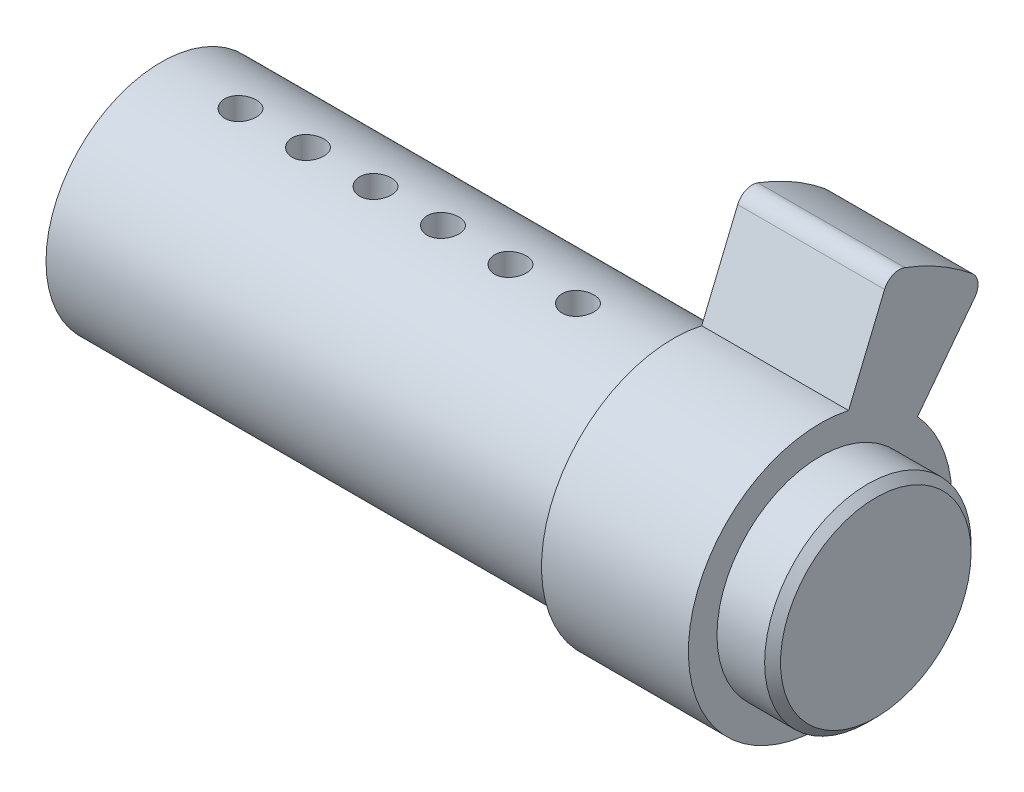
from build123d import *

# Parameters (mm, degrees)
SKETCH1_R           = 7.25
OUTSIDE_DIA_DEPTH   = 32.25
SKETCH2_W           = 2.5
SKETCH2_H           = 8.25
KEYHOLE_DEPTH       = 33.25
SKETCH3_R           = 1
PIN_1_DEPTH         = 35
LPATTERN1_COUNT     = 6
LPATTERN1_PITCH     = 4.25
CAM_DEPTH           = 9.25
FILLET_R1_R         = 1
SKETCH6_R           = 6.5
END_BIT_DEPTH       = 3.5
F_0_5_X_45_DEG_SIZE = 0.5


with BuildPart() as part:
    # Sketch1 → outside dia (new body)
    with BuildSketch(Plane(origin=(0, 0, 0), x_dir=(0, 0, -1), z_dir=(1, 0, 0))):
        Circle(SKETCH1_R)
    extrude(amount=OUTSIDE_DIA_DEPTH)

    # Sketch2 → keyhole (cut, through all)
    with BuildSketch(Plane.ZY):
        with Locations((0, -2.125)):
            Rectangle(SKETCH2_W, SKETCH2_H)
    extrude(amount=-KEYHOLE_DEPTH, mode=Mode.SUBTRACT)

    # Sketch3 → pin 1 (cut)
    with BuildSketch(Plane(origin=(0, 0, 0), x_dir=(1, 0, 0), z_dir=(0, 1, 0))):
        with Locations((5, 0)):
            Circle(SKETCH3_R)
    pin_1 = extrude(amount=PIN_1_DEPTH, mode=Mode.SUBTRACT)

    # LPattern1: pin 1 ×6
    with Locations(*[(i * LPATTERN1_PITCH, 0, 0) for i in range(1, LPATTERN1_COUNT)]):
        add(pin_1, mode=Mode.SUBTRACT)

    # Sketch4 → front cone 5.5 x 90 deg (revolve, cut)
    with BuildSketch(Plane.XY):
        Polygon((0, -3.5), (0, -6.25), (2.75, -3.5), align=None)
    revolve(axis=Axis((2.75, -3.5, 0), (-1, 0, 0)), mode=Mode.SUBTRACT)

    # Sketch5 → cam (add)
    with BuildSketch(Plane(origin=(32.25, 0, 0), x_dir=(0, 0, -1), z_dir=(1, 0, 0))):
        with BuildLine():
            Line((4.411633528, 14.441173415), (1.787227075, 8.105295762))
            ThreePointArc((1.787227075, 8.105295762), (-4.15, -7.188010851), (6.125778497, 5.60043193))
            Line((6.125778497, 5.60043193), (10.300606274, 11.041173415))
            ThreePointArc((10.300606274, 11.041173415), (7.55, 13.076983597), (4.411633528, 14.441173415))
        make_face()
    extrude(amount=CAM_DEPTH)

    # Fillet R1
    fillet_r1_edges = [part.edges().sort_by_distance(p)[0] for p in [
        (36.875, 11.041173415, -10.300606274),
        (36.875, 14.441173415, -4.411633528),
    ]]
    fillet(fillet_r1_edges, radius=FILLET_R1_R)

    # Sketch6 → end bit (add)
    with BuildSketch(Plane(origin=(41.5, 0, 0), x_dir=(0, 0, -1), z_dir=(1, 0, 0))):
        Circle(SKETCH6_R)
    extrude(amount=END_BIT_DEPTH)

    # 0.5 x 45 deg
    f_0_5_x_45_deg_edges = [part.edges().sort_by_distance(p)[0] for p in [
        (45, 0, 6.5),
    ]]
    chamfer(f_0_5_x_45_deg_edges, length=F_0_5_X_45_DEG_SIZE)


solid = part.part
